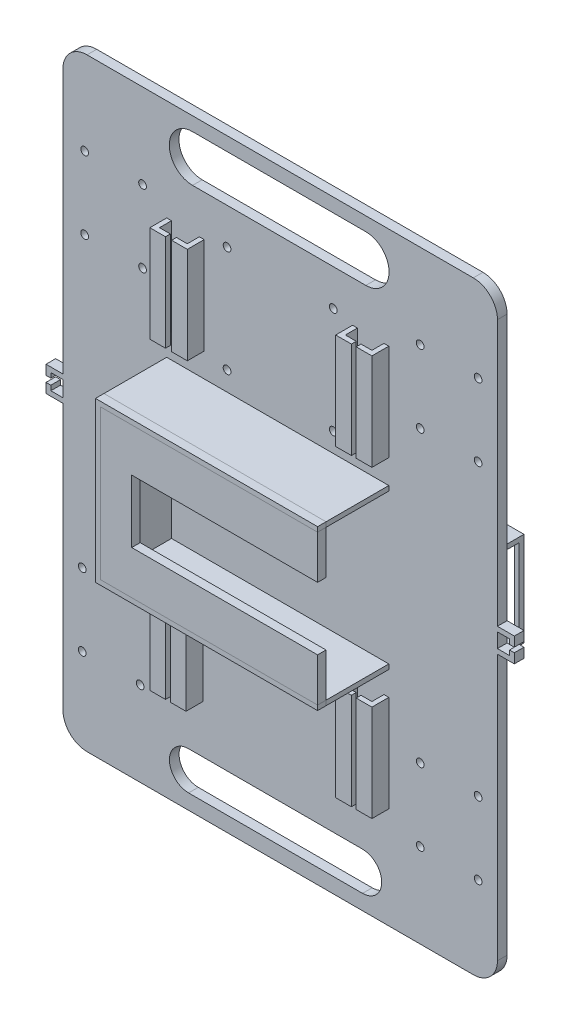
from build123d import *

# Parameters (mm, degrees)
SKETCH_2_R          = 1.6
EXTRUDE_1_DEPTH     = 4
EXTRUDE_2_DEPTH     = 26
SKETCH_5_W          = 13
SKETCH_5_H          = 26
EXTRUDE_3_DEPTH     = 3.5
EXTRUDE_4_DEPTH     = 3.5
SKETCH_7_W          = 2
SKETCH_7_H          = 40
EXTRUDE_5_DEPTH     = 5
SKETCH_8_W          = 6.5
SKETCH_8_H          = 40
EXTRUDE_6_DEPTH     = 2
SKETCH_11_W         = 2
SKETCH_11_H         = 40
EXTRUDE_7_DEPTH     = 5
SKETCH_12_W         = 2
SKETCH_12_H         = 40
EXTRUDE_8_DEPTH     = 5
SKETCH_13_W         = 6.5
SKETCH_13_H         = 40
EXTRUDE_9_DEPTH     = 2
SKETCH_14_W         = 6.5
SKETCH_14_H         = 40
EXTRUDE_10_DEPTH    = 2
SKETCH_16_R         = 1.6
CUT_EXTRUDE_1_DEPTH = 5
SKETCH_20_W         = 35
SKETCH_20_H         = 35
EXTRUDE_12_DEPTH    = 20
SKETCH_21_W         = 18
SKETCH_21_H         = 35
CUT_EXTRUDE_2_DEPTH = 60
SKETCH_22_W         = 3
SKETCH_22_H         = 35
EXTRUDE_13_DEPTH    = 1
SKETCH_23_W         = 3
SKETCH_23_H         = 35
EXTRUDE_18_DEPTH    = 1
SKETCH_24_W         = 39
SKETCH_24_H         = 39
SKETCH_24_W_2       = 35
SKETCH_24_H_2       = 35
EXTRUDE_19_DEPTH    = 20
SKETCH_25_W         = 12
SKETCH_25_H         = 32
CUT_EXTRUDE_3_DEPTH = 50
SKETCH_26_W         = 4
SKETCH_26_H         = 2
EXTRUDE_20_DEPTH    = 5
SKETCH_27_W         = 4
SKETCH_27_H         = 4
EXTRUDE_21_DEPTH    = 2
SKETCH_28_W         = 4
SKETCH_28_H         = 2
EXTRUDE_22_DEPTH    = 5
SKETCH_29_W         = 4
SKETCH_29_H         = 4
EXTRUDE_23_DEPTH    = 2
CUT_EXTRUDE_4_DEPTH = 10


with BuildPart() as part:
    # 草图2 → 凸台-拉伸1 (new body)
    with BuildSketch(Plane.XY):
        with BuildLine():
            Line((-97.180739019, 63.077036811), (62.819260981, 63.077036811))
            ThreePointArc((62.819260981, 63.077036811), (69.890328793, 60.148104623), (72.819260981, 53.077036811))
            Line((72.819260981, 53.077036811), (72.819260981, -176.922963189))
            ThreePointArc((72.819260981, -176.922963189), (69.890328793, -183.994031001), (62.819260981, -186.922963189))
            Line((62.819260981, -186.922963189), (-97.180739019, -186.922963189))
            ThreePointArc((-97.180739019, -186.922963189), (-104.251806831, -183.994031001), (-107.180739019, -176.922963189))
            Line((-107.180739019, -176.922963189), (-107.180739019, 53.077036811))
            ThreePointArc((-107.180739019, 53.077036811), (-104.251806831, 60.148104623), (-97.180739019, 63.077036811))
        make_face()
        with Locations((-99.180739019, -151.922963189)):
            Circle(SKETCH_2_R, mode=Mode.SUBTRACT)
        with Locations((-99.180739019, -121.922963189)):
            Circle(SKETCH_2_R, mode=Mode.SUBTRACT)
        with Locations((-75.180739019, -121.922963189)):
            Circle(SKETCH_2_R, mode=Mode.SUBTRACT)
        with Locations((-75.180739019, -151.922963189)):
            Circle(SKETCH_2_R, mode=Mode.SUBTRACT)
        with Locations((64.819260981, -151.922963189)):
            Circle(SKETCH_2_R, mode=Mode.SUBTRACT)
        with Locations((40.819260981, -151.922963189)):
            Circle(SKETCH_2_R, mode=Mode.SUBTRACT)
        with Locations((40.819260981, -121.922963189)):
            Circle(SKETCH_2_R, mode=Mode.SUBTRACT)
        with Locations((64.819260981, -121.922963189)):
            Circle(SKETCH_2_R, mode=Mode.SUBTRACT)
        with Locations((-98.180739019, 28.077036811)):
            Circle(SKETCH_2_R, mode=Mode.SUBTRACT)
        with Locations((-98.180739019, -1.922963189)):
            Circle(SKETCH_2_R, mode=Mode.SUBTRACT)
        with Locations((-74.180739019, 28.077036811)):
            Circle(SKETCH_2_R, mode=Mode.SUBTRACT)
        with Locations((-74.180739019, -1.922963189)):
            Circle(SKETCH_2_R, mode=Mode.SUBTRACT)
        with Locations((40.819260981, 28.077036811)):
            Circle(SKETCH_2_R, mode=Mode.SUBTRACT)
        with Locations((64.819260981, 28.077036811)):
            Circle(SKETCH_2_R, mode=Mode.SUBTRACT)
        with Locations((40.819260981, -1.922963189)):
            Circle(SKETCH_2_R, mode=Mode.SUBTRACT)
        with Locations((64.819260981, -1.922963189)):
            Circle(SKETCH_2_R, mode=Mode.SUBTRACT)
    extrude(amount=EXTRUDE_1_DEPTH)

    # 草图3 → 凸台-拉伸2 (add)
    with BuildSketch(Plane.XY.offset(4)):
        Polygon((27.819260981, -30.922963189), (-62.180739019, -30.922963189), (-62.180739019, -92.922963189), (27.819260981, -92.922963189), (27.819260981, -94.922963189), (-64.180739019, -94.922963189), (-64.180739019, -28.922963189), (27.819260981, -28.922963189), align=None)
    extrude(amount=EXTRUDE_2_DEPTH)

    # 草图7 → 凸台-拉伸5 (add)
    with BuildSketch(Plane.XY.offset(4)):
        with Locations((-63.180739019, -124.922963189)):
            Rectangle(SKETCH_7_W, SKETCH_7_H)
        with Locations((-50.180739019, -124.922963189)):
            Rectangle(SKETCH_7_W, SKETCH_7_H)
        with Locations((13.819260981, -124.922963189)):
            Rectangle(SKETCH_7_W, SKETCH_7_H)
        with Locations((26.819260981, -124.922963189)):
            Rectangle(SKETCH_7_W, SKETCH_7_H)
    extrude(amount=EXTRUDE_5_DEPTH)

    # 草图8 → 凸台-拉伸6 (add)
    with BuildSketch(Plane.XY.offset(9)):
        with Locations((-60.930739019, -124.922963189)):
            Rectangle(SKETCH_8_W, SKETCH_8_H)
        with Locations((-52.430739019, -124.922963189)):
            Rectangle(SKETCH_8_W, SKETCH_8_H)
        with Locations((16.069260981, -124.922963189)):
            Rectangle(SKETCH_8_W, SKETCH_8_H)
        with Locations((24.569260981, -124.922963189)):
            Rectangle(SKETCH_8_W, SKETCH_8_H)
    extrude(amount=EXTRUDE_6_DEPTH)

    # 草图11 → 凸台-拉伸7 (add)
    with BuildSketch(Plane.XY.offset(4)):
        with Locations((-49.648958747, 1.077036811)):
            Rectangle(SKETCH_11_W, SKETCH_11_H)
        with Locations((26.819260981, 1.077036811)):
            Rectangle(SKETCH_11_W, SKETCH_11_H)
        with Locations((13.819260981, 1.077036811)):
            Rectangle(SKETCH_11_W, SKETCH_11_H)
    extrude(amount=EXTRUDE_7_DEPTH)

    # 草图12 → 凸台-拉伸8 (add)
    with BuildSketch(Plane.XY.offset(4)):
        with Locations((-63.180739019, 1.077036811)):
            Rectangle(SKETCH_12_W, SKETCH_12_H)
    extrude(amount=EXTRUDE_8_DEPTH)

    # 草图13 → 凸台-拉伸9 (add)
    with BuildSketch(Plane.XY.offset(9)):
        with Locations((-60.930739019, 1.077036811)):
            Rectangle(SKETCH_13_W, SKETCH_13_H)
    extrude(amount=EXTRUDE_9_DEPTH)

    # 草图14 → 凸台-拉伸10 (add)
    with BuildSketch(Plane.XY.offset(9)):
        with Locations((-51.898958747, 1.077036811)):
            Rectangle(SKETCH_14_W, SKETCH_14_H)
        with Locations((24.569260981, 1.077036811)):
            Rectangle(SKETCH_14_W, SKETCH_14_H)
        with Locations((16.069260981, 1.077036811)):
            Rectangle(SKETCH_14_W, SKETCH_14_H)
    extrude(amount=EXTRUDE_10_DEPTH)

    # 草图16 → 切除-拉伸1 (cut)
    with BuildSketch(Plane(origin=(0, 0, 0), x_dir=(-1, 0, 0), z_dir=(0, 0, -1))):
        with Locations((-4.819260981, 23.077036811)):
            Circle(SKETCH_16_R)
        with Locations((39.180739019, 23.077036811)):
            Circle(SKETCH_16_R)
        with Locations((39.180739019, -20.922963189)):
            Circle(SKETCH_16_R)
        with Locations((-4.819260981, -20.922963189)):
            Circle(SKETCH_16_R)
    extrude(amount=-CUT_EXTRUDE_1_DEPTH, mode=Mode.SUBTRACT)

    # 草图20 → 凸台-拉伸12 (add)
    with BuildSketch(Plane(origin=(0, 0, 0), x_dir=(-1, 0, 0), z_dir=(0, 0, -1))):
        Polygon((-22.819260981, -42.422963189), (-59.819260981, -42.422963189), (-59.819260981, -81.422963189), (-20.819260981, -81.422963189), (-20.819260981, -42.422963189), align=None)
        with Locations((-40.319260981, -61.922963189)):
            Rectangle(SKETCH_20_W, SKETCH_20_H, mode=Mode.SUBTRACT)
    extrude(amount=EXTRUDE_12_DEPTH)

    # 草图21 → 切除-拉伸2 (cut)
    with BuildSketch(Plane.ZY.offset(-20.819260981)):
        with Locations((-9, -61.922963189)):
            Rectangle(SKETCH_21_W, SKETCH_21_H)
    extrude(amount=-CUT_EXTRUDE_2_DEPTH, mode=Mode.SUBTRACT)

    # 草图22 → 凸台-拉伸13 (add)
    with BuildSketch(Plane(origin=(59.819260981, 0, 0), x_dir=(0, 0, -1), z_dir=(1, 0, 0))):
        with Locations((1.5, -61.922963189)):
            Rectangle(SKETCH_22_W, SKETCH_22_H)
    extrude(amount=-EXTRUDE_13_DEPTH)

    # 草图23 → 凸台-拉伸18 (add)
    with BuildSketch(Plane.ZY.offset(-20.819260981)):
        with Locations((-1.5, -61.922963189)):
            Rectangle(SKETCH_23_W, SKETCH_23_H)
    extrude(amount=-EXTRUDE_18_DEPTH)

    # 草图24 → 凸台-拉伸19 (add)
    with BuildSketch(Plane(origin=(0, 0, 0), x_dir=(-1, 0, 0), z_dir=(0, 0, -1))):
        with Locations((74.313659909, -61.922963189)):
            Rectangle(SKETCH_24_W, SKETCH_24_H)
        with Locations((74.680739019, -61.922963189)):
            Rectangle(SKETCH_24_W_2, SKETCH_24_H_2, mode=Mode.SUBTRACT)
    extrude(amount=EXTRUDE_19_DEPTH)

    # 草图25 → 切除-拉伸3 (cut)
    with BuildSketch(Plane.ZY.offset(93.813659909)):
        with Locations((-9, -60.422963189)):
            Rectangle(SKETCH_25_W, SKETCH_25_H)
    extrude(amount=-CUT_EXTRUDE_3_DEPTH, mode=Mode.SUBTRACT)

    # 草图26 → 凸台-拉伸20 (add)
    with BuildSketch(Plane(origin=(72.819260981, 0, 0), x_dir=(0, 0, -1), z_dir=(1, 0, 0))):
        with Locations((-2, -57.922963189)):
            Rectangle(SKETCH_26_W, SKETCH_26_H)
        with Locations((-2, -65.922963189)):
            Rectangle(SKETCH_26_W, SKETCH_26_H)
    extrude(amount=EXTRUDE_20_DEPTH)

    # 草图27 → 凸台-拉伸21 (add)
    with BuildSketch(Plane(origin=(77.819260981, 0, 0), x_dir=(0, 0, -1), z_dir=(1, 0, 0))):
        with Locations((-2, -58.922963189)):
            Rectangle(SKETCH_27_W, SKETCH_27_H)
        with Locations((-2, -64.922963189)):
            Rectangle(SKETCH_27_W, SKETCH_27_H)
    extrude(amount=EXTRUDE_21_DEPTH)

    # 草图28 → 凸台-拉伸22 (add)
    with BuildSketch(Plane.ZY.offset(107.180739019)):
        with Locations((2, -57.402028862)):
            Rectangle(SKETCH_28_W, SKETCH_28_H)
        with Locations((2, -65.922963189)):
            Rectangle(SKETCH_28_W, SKETCH_28_H)
    extrude(amount=EXTRUDE_22_DEPTH)

    # 草图29 → 凸台-拉伸23 (add)
    with BuildSketch(Plane.ZY.offset(112.180739019)):
        with Locations((2, -58.402028862)):
            Rectangle(SKETCH_29_W, SKETCH_29_H)
        with Locations((2, -64.922963189)):
            Rectangle(SKETCH_29_W, SKETCH_29_H)
    extrude(amount=EXTRUDE_23_DEPTH)

    # 草图33 → 切除-拉伸4 (cut)
    with BuildSketch(Plane.XY.offset(4)):
        with BuildLine():
            Line((-53.478478511, 57.37323989), (18.307022946, 57.37323989))
            ThreePointArc((18.307022946, 57.37323989), (27.939582246, 47.74068059), (18.307022946, 38.108121289))
            Line((18.307022946, 38.108121289), (-53.478478511, 38.108121289))
            ThreePointArc((-53.478478511, 38.108121289), (-63.111037812, 47.74068059), (-53.478478511, 57.37323989))
        make_face()
        with BuildLine():
            Line((-55.128461236, -164.815051306), (16.932082734, -164.815051306))
            ThreePointArc((16.932082734, -164.815051306), (24.86327468, -172.746243252), (16.932082734, -180.677435198))
            Line((16.932082734, -180.677435198), (-55.128461236, -180.677435198))
            ThreePointArc((-55.128461236, -180.677435198), (-63.059653182, -172.746243252), (-55.128461236, -164.815051306))
        make_face()
    extrude(amount=-CUT_EXTRUDE_4_DEPTH, mode=Mode.SUBTRACT)


with BuildPart() as body_2:
    # 草图5 → 凸台-拉伸3 (new body)
    with BuildSketch(Plane.XY.offset(30)):
        Polygon((27.819260981, -48.922963189), (27.819260981, -30.922963189), (-62.180739019, -30.922963189), (-62.180739019, -48.922963189), (-49.180739019, -48.922963189), align=None)
        Polygon((27.819260981, -74.922963189), (-49.180739019, -74.922963189), (-62.180739019, -74.922963189), (-62.180739019, -92.922963189), (27.819260981, -92.922963189), align=None)
        with Locations((-55.680739019, -61.922963189)):
            Rectangle(SKETCH_5_W, SKETCH_5_H)
    extrude(amount=EXTRUDE_3_DEPTH)


with BuildPart() as body_3:
    # 草图6 → 凸台-拉伸4 (new body)
    with BuildSketch(Plane.XY.offset(33.5)):
        Polygon((27.819260981, -30.922963189), (27.819260981, -28.922963189), (-64.180739019, -28.922963189), (-64.180739019, -94.922963189), (27.819260981, -94.922963189), (27.819260981, -92.922963189), (-62.180739019, -92.922963189), (-62.180739019, -30.922963189), align=None)
    extrude(amount=-EXTRUDE_4_DEPTH)


solid = Compound([part.part, body_2.part, body_3.part])
